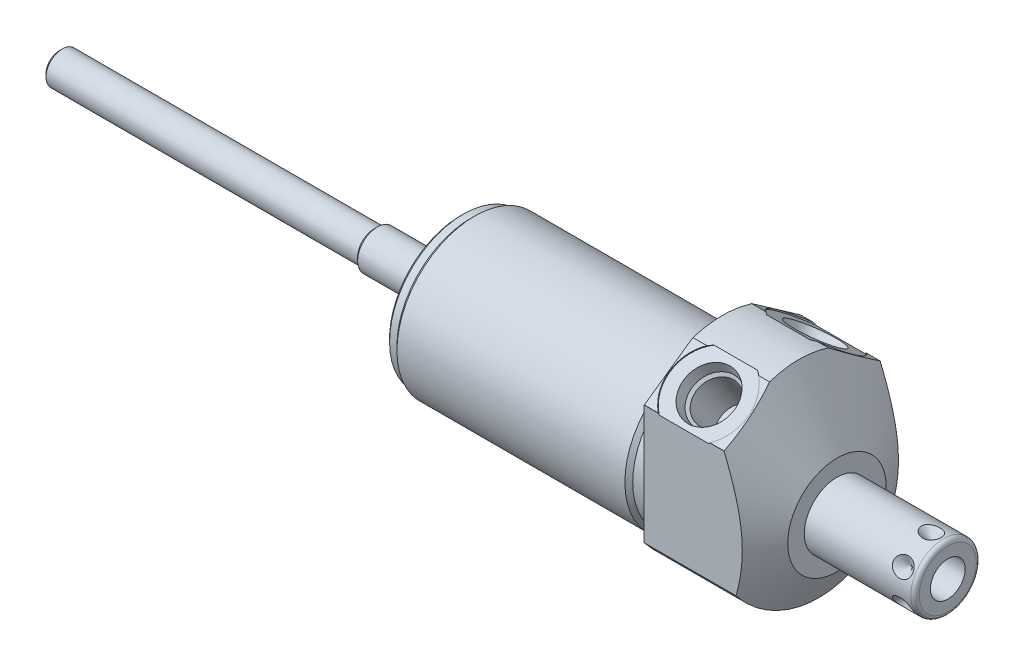
from build123d import *

# Parameters (mm, degrees)
SKETCH1_R           = 23.8125
EXTRUDE1_DEPTH      = 27.7876
EXTRUDE1_DEPTH_BACK = 63.5
CUT_EXTRUDE1_REACH  = 65.5
SKETCH2_R           = 23.8125
SKETCH2_R_2         = 18.8595
CUT_EXTRUDE3_START  = -27.7876
SKETCH4_R           = 28.575
CUT_EXTRUDE3_DEPTH  = 27.7876
SKETCH18_R          = 9.525
CUT_EXTRUDE4_DEPTH  = 0.254
SKETCH19_R          = 9.525
CUT_EXTRUDE5_DEPTH  = 0.254
CHAMFER1_SIZE       = 0.762
CIRPATTERN1_COUNT   = 6
SKETCH20_R          = 15.875
EXTRUDE2_DEPTH      = 1.016
CUT_EXTRUDE6_DEPTH  = 1.524
SKETCH22_R          = 16.129
SKETCH22_R_2        = 15.875
CUT_EXTRUDE7_DEPTH  = 2.54
CHAMFER2_SIZE       = 0.762


with BuildPart() as part:
    # Sketch1 → Extrude1 (new body, two sides)
    with BuildSketch(Plane(origin=(0, 0, 0), x_dir=(0, 0, -1), z_dir=(1, 0, 0))) as extrude1_sk:
        Circle(SKETCH1_R)
    extrude(amount=EXTRUDE1_DEPTH)
    extrude(extrude1_sk.sketch, amount=-EXTRUDE1_DEPTH_BACK)

    # Sketch2 → Cut-Extrude1 (cut, up to next)
    with BuildSketch(Plane(origin=(0, 0, 0), x_dir=(0, 0, -1), z_dir=(1, 0, 0)), mode=Mode.PRIVATE) as cut_extrude1_sk1:
        Circle(SKETCH2_R)
        with Locations((0, -4.191)):
            Circle(SKETCH2_R_2, mode=Mode.SUBTRACT)
    cut_extrude1_tool1 = extrude(cut_extrude1_sk1.sketch, amount=-CUT_EXTRUDE1_REACH, mode=Mode.PRIVATE) & part.part
    add(cut_extrude1_tool1.solids().sort_by_distance((0, 0, 23.138981))[0], mode=Mode.SUBTRACT)

    # Sketch4 → Cut-Extrude3 (cut)
    with BuildSketch(Plane.ZY.offset(CUT_EXTRUDE3_START)):
        Circle(SKETCH4_R)
        with BuildLine():
            Line((18.923, -14.455283714), (18.923, 14.465869871))
            Line((18.923, 14.465869871), (0, 27.715897117))
            Line((0, 27.715897117), (-18.923, 14.465869871))
            Line((-18.923, 14.465869871), (-18.923, -14.455283714))
            ThreePointArc((-18.923, -14.455283714), (0, -23.8125), (18.923, -14.455283714))
        make_face(mode=Mode.SUBTRACT)
    extrude(amount=CUT_EXTRUDE3_DEPTH, mode=Mode.SUBTRACT)

    # Sketch6 → Cut-Revolve2 (revolve, cut)
    with BuildSketch(Plane.XY, mode=Mode.PRIVATE) as cut_revolve2_sk:
        Polygon((4.764025965, 47.625), (27.7876, 7.747), (27.7876, 47.625), align=None)
    revolve(cut_revolve2_sk.sketch.rotate(Axis((3.612847264, -4.191, 0), (1, 0, 0)), 270), axis=Axis((3.612847264, -4.191, 0), (1, 0, 0)), mode=Mode.SUBTRACT)  # turned: the seam where the file's is

    # S2D0002 → Cut-Revolve3 (revolve, cut)
    with BuildSketch(Plane(origin=(9.652, 18.394824642, 12.869035589), x_dir=(0, 0.573576436, -0.819152044), z_dir=(1, 0, 0))):
        Polygon((0, 0), (6.1849, 0), (5.642306865, -2.5527), (4.9784, -3.216606865), (4.9784, -13.462), (0, -13.462), align=None)
    revolve(axis=Axis((9.652, 6.816028581, 4.761475303), (0, 0.819152044, 0.573576436)), mode=Mode.SUBTRACT)

    # Sketch8 → Cut-Revolve4 (revolve, cut)
    with BuildSketch(Plane(origin=(9.652, 18.394824642, -12.869035589), x_dir=(0, -0.573576436, -0.819152044), z_dir=(1, 0, 0))):
        Polygon((0, 0), (6.1849, 0), (5.642306865, -2.5527), (4.9784, -3.216606865), (4.9784, -13.462), (0, -13.462), align=None)
    revolve(axis=Axis((9.652, 6.816028581, -4.761475303), (0, 0.819152044, -0.573576436)), mode=Mode.SUBTRACT)

    # Sketch18 → Cut-Extrude4 (cut)
    with BuildSketch(Plane(origin=(0, 18.59764611, 13.022211999), x_dir=(1, 0, 0), z_dir=(0, 0.819152044, 0.573576436))):
        with Locations((9.652, 0.009141155)):
            Circle(SKETCH18_R)
    extrude(amount=-CUT_EXTRUDE4_DEPTH, mode=Mode.SUBTRACT)

    # Sketch19 → Cut-Extrude5 (cut)
    with BuildSketch(Plane(origin=(0, 18.59764611, -13.022211999), x_dir=(1, 0, 0), z_dir=(0, 0.819152044, -0.573576436))):
        with Locations((9.652, -0.009141155)):
            Circle(SKETCH19_R)
    extrude(amount=-CUT_EXTRUDE5_DEPTH, mode=Mode.SUBTRACT)

    # Sketch10 → Cut-Revolve6 (revolve, cut)
    with BuildSketch(Plane.XY, mode=Mode.PRIVATE) as cut_revolve6_sk:
        Polygon((0, 14.6685), (0, 13.716), (-3.81, 13.716), (-4.7625, 14.6685), align=None)
    revolve(cut_revolve6_sk.sketch.rotate(Axis((-5.000625, -4.191, 0), (1, 0, 0)), 90), axis=Axis((-5.000625, -4.191, 0), (1, 0, 0)), mode=Mode.SUBTRACT)  # turned: the seam where the file's is

    # Sketch12 → Cut-Revolve8 (revolve, cut)
    with BuildSketch(Plane.XY, mode=Mode.PRIVATE) as cut_revolve8_sk:
        Polygon((-63.5, 14.6685), (-63.5, 13.716), (-60.96, 13.716), (-60.0075, 14.6685), align=None)
    revolve(cut_revolve8_sk.sketch.rotate(Axis((-63.674625, -4.191, 0), (1, 0, 0)), 90), axis=Axis((-63.674625, -4.191, 0), (1, 0, 0)), mode=Mode.SUBTRACT)  # turned: the seam where the file's is

    # Chamfer1
    chamfer1_edges = [part.edges().sort_by_distance(p)[0] for p in [
        (-63.5, -4.191, -17.907),
    ]]
    chamfer(chamfer1_edges, length=CHAMFER1_SIZE)

    # Sketch13 → Revolve1 (revolve)
    with BuildSketch(Plane(origin=(0, 0, 0), x_dir=(0, -1, 0), z_dir=(0, 0, 1)), mode=Mode.PRIVATE) as revolve1_sk:
        with BuildLine():
            Line((4.191, 27.7876), (4.191, 54.6354))
            Line((4.191, 54.6354), (11.1125, 54.6354))
            ThreePointArc((11.1125, 54.6354), (11.83092049, 54.33782049), (12.1285, 53.6194))
            Line((12.1285, 53.6194), (12.1285, 27.7876))
            Line((12.1285, 27.7876), (4.191, 27.7876))
        make_face()
    revolve(revolve1_sk.sketch.rotate(Axis((26.44521, -4.191, 0), (1, 0, 0)), 270), axis=Axis((26.44521, -4.191, 0), (1, 0, 0)))  # turned: the seam where the file's is

    # S2D0001 → Cut-Revolve9 (revolve, cut)
    with BuildSketch(Plane(origin=(54.6354, -8.4074, 0), x_dir=(0, -1, 0), z_dir=(0, 0, 1)), mode=Mode.PRIVATE) as cut_revolve9_sk:
        Polygon((0, 0), (0, -15.24), (-4.2164, -17.773468714), (-4.2164, 0), align=None)
    revolve(cut_revolve9_sk.sketch.rotate(Axis((35.97325785, -4.191, 0), (1, 0, 0)), 270), axis=Axis((35.97325785, -4.191, 0), (1, 0, 0)), mode=Mode.SUBTRACT)  # turned: the seam where the file's is

    # Sketch16 → Cut-Revolve10 (revolve, cut)
    with BuildSketch(Plane(origin=(50.673, 3.7465, 0), x_dir=(-1, 0, 0), z_dir=(0, 0, -1)), mode=Mode.PRIVATE) as cut_revolve10_sk:
        Polygon((0, 0), (2.413, 0), (0, -2.413), align=None)
    cut_revolve10 = revolve(cut_revolve10_sk.sketch.rotate(Axis((50.673, -1.324519499, 0), (0, 1, 0)), 90), axis=Axis((50.673, -1.324519499, 0), (0, 1, 0)), mode=Mode.SUBTRACT)  # turned: the seam where the file's is

    # CirPattern1: Cut-Revolve10 ×6 about axis
    cirpattern1_axis = Axis((26.44521, -4.191, 0), (-1, 0, 0))
    for i in range(1, CIRPATTERN1_COUNT):
        add(cut_revolve10.rotate(cirpattern1_axis, i * 360 / CIRPATTERN1_COUNT), mode=Mode.SUBTRACT)

    # Sketch20 → Extrude2 (add)
    with BuildSketch(Plane.ZY.offset(63.5)):
        with Locations(Location((0, -4.191, 0), (0, 0, 180))):  # turned: the seam where the file's is
            Circle(SKETCH20_R)
    extrude(amount=EXTRUDE2_DEPTH)

    # Sketch21 → Cut-Extrude6 (cut)
    with BuildSketch(Plane.ZY.offset(64.516)):
        with BuildLine():
            Line((8.642842216, -2.9972), (15.830049481, -2.9972))
            ThreePointArc((15.830049481, -2.9972), (15.875, -4.191), (15.830049481, -5.3848))
            Line((15.830049481, -5.3848), (8.642842216, -5.3848))
            ThreePointArc((8.642842216, -5.3848), (0, -12.9159), (-8.642842216, -5.3848))
            Line((-8.642842216, -5.3848), (-15.830049481, -5.3848))
            ThreePointArc((-15.830049481, -5.3848), (-15.875, -4.191), (-15.830049481, -2.9972))
            Line((-15.830049481, -2.9972), (-8.642842216, -2.9972))
            ThreePointArc((-8.642842216, -2.9972), (0, 4.5339), (8.642842216, -2.9972))
        make_face()
    extrude(amount=-CUT_EXTRUDE6_DEPTH, mode=Mode.SUBTRACT)

    # Sketch22 → Cut-Extrude7 (cut)
    with BuildSketch(Plane.ZY.offset(64.516)):
        with Locations((0, -4.191)):
            Circle(SKETCH22_R)
        with Locations(Location((0, -4.191, 0), (0, 0, 175.687286087))):  # turned: the seam where the file's is
            Circle(SKETCH22_R_2, mode=Mode.SUBTRACT)
    extrude(amount=-CUT_EXTRUDE7_DEPTH, mode=Mode.SUBTRACT)

    # Sketch23 → Revolve2 (revolve)
    with BuildSketch(Plane.XY, mode=Mode.PRIVATE) as revolve2_sk:
        Polygon((-62.992, 0.5715), (-83.6168, 0.5715), (-84.4169, -0.2286), (-160.7058, -0.2286), (-160.7058, -4.191), (-62.738, -4.191), align=None)
    revolve(revolve2_sk.sketch.rotate(Axis((-64.687416789, -4.191, 0), (-1, 0, 0)), 270), axis=Axis((-64.687416789, -4.191, 0), (-1, 0, 0)))  # turned: the seam where the file's is

    # Chamfer2
    chamfer2_edges = [part.edges().sort_by_distance(p)[0] for p in [
        (-64.516, 11.684, 0),
        (-64.516, -20.066, 0),
        (-160.7058, -4.191, -3.9624),
    ]]
    chamfer(chamfer2_edges, length=CHAMFER2_SIZE)


solid = part.part
